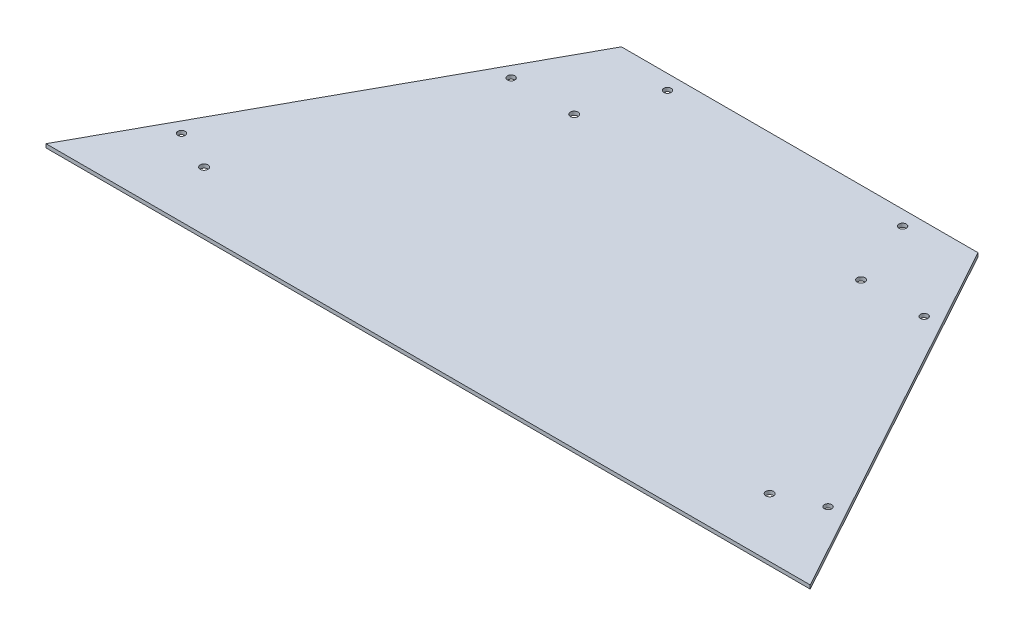
from build123d import *

# Parameters (mm, degrees)
BOSS_EXTRUDE1_DEPTH         = 3.175
F_1_4_0_25_DIAMETER_HOLE1_D = 6.35
F_1_4_CLEARANCE_HOLE1_D     = 6.7564


with BuildPart() as part:
    # Sketch1 → Boss-Extrude1 (new body)
    with BuildSketch(Plane(origin=(0, 0, 0), x_dir=(1, 0, 0), z_dir=(0, 1, 0))):
        Polygon((-330.2, 0), (-154.051, 321.128911223), (154.051, 321.128911223), (330.2, 0), align=None)
    extrude(amount=BOSS_EXTRUDE1_DEPTH)

    # 1/4 (0.25) Diameter Hole1 (through all)
    with Locations(Plane(origin=(0, 3.175, 0), x_dir=(1, 0, 0), z_dir=(0, 1, 0))):
        with Locations((-279.364444826, 66.268686649), (-178.463561331, 250.216315407), (-101.6, 308.428911223), (279.364444826, 66.268686649), (178.463561331, 250.216315407), (101.6, 308.428911223)):
            Hole(F_1_4_0_25_DIAMETER_HOLE1_D / 2)

    # 1/4 Clearance Hole1 (through all)
    with Locations(Plane(origin=(0, 3.175, 0), x_dir=(1, 0, 0), z_dir=(0, 1, 0))):
        with Locations((-123.952, 250.216315407), (-244.348, 50.8), (244.348, 50.8), (123.952, 250.216315407)):
            Hole(F_1_4_CLEARANCE_HOLE1_D / 2)


solid = part.part
